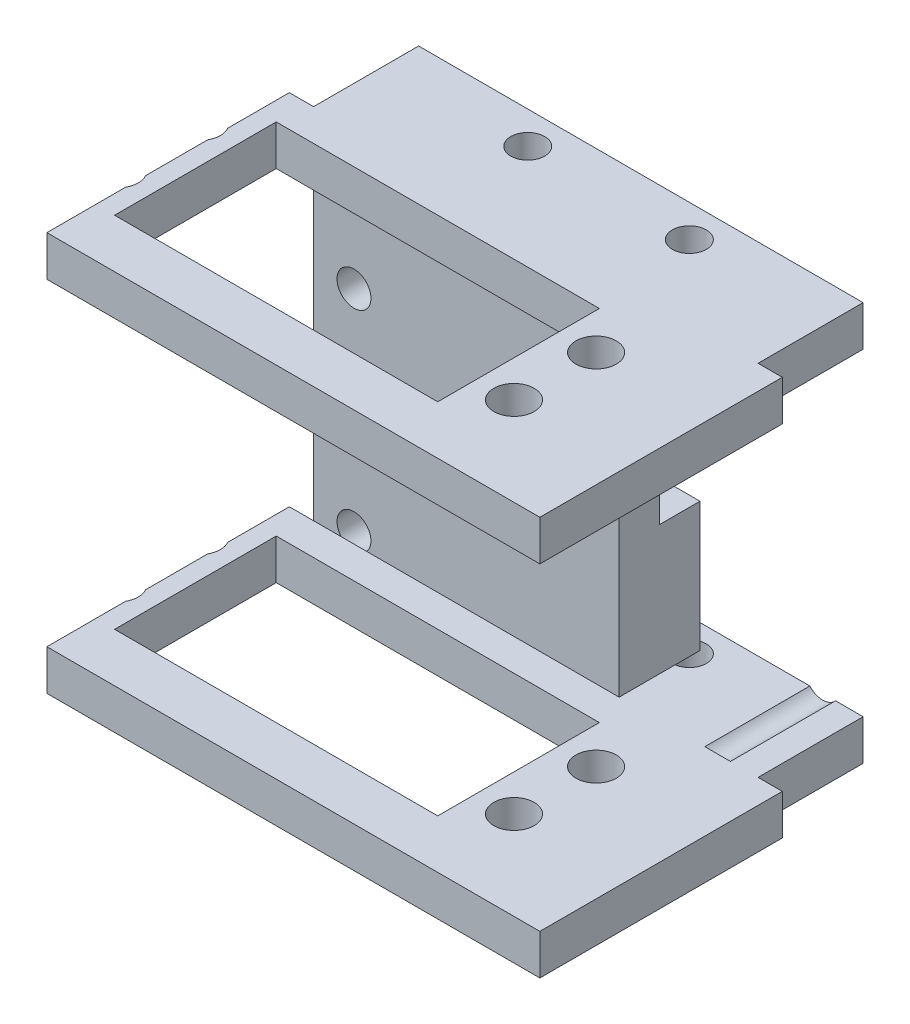
from build123d import *

# Parameters (mm, degrees)
BOSS_EXTRUDE1_DEPTH   = 5
BOSS_EXTRUDE1_2_DEPTH = 5
BOSS_EXTRUDE1_3_DEPTH = 5
BOSS_EXTRUDE1_4_DEPTH = 5
SKETCH2_W             = 37.8125
SKETCH2_H             = 39.375
BOSS_EXTRUDE2_DEPTH   = 5
SKETCH3_W             = 55
SKETCH3_H             = 13
SKETCH3_R             = 2.1
BOSS_EXTRUDE3_DEPTH   = 5
SKETCH4_W             = 61
SKETCH4_H             = 30
BOSS_EXTRUDE4_DEPTH   = 5
SKETCH5_R             = 2.5
SKETCH5_W             = 39.983210939
SKETCH5_H             = 20
CUT_EXTRUDE3_DEPTH    = 5
SKETCH7_R             = 2.1
CUT_EXTRUDE4_DEPTH    = 14


with BuildPart() as part:
    # Sketch1 → Boss-Extrude1 (new body)
    with BuildSketch(Plane.XY):
        with BuildLine():
            Line((16.390676557, 6.279692656), (19.828176557, 6.279692656))
            Line((19.828176557, 6.279692656), (19.828176557, 17.279692656))
            Line((19.828176557, 17.279692656), (13.640676557, 17.279692656))
            Line((13.640676557, 17.279692656), (13.640676557, 9.029692656))
            ThreePointArc((13.640676557, 9.029692656), (14.446132909, 7.085149007), (16.390676557, 6.279692656))
        make_face()
    extrude(amount=BOSS_EXTRUDE1_DEPTH)



with BuildPart() as body_2:
    # Sketch1 → Boss-Extrude1 2 (new body)
    with BuildSketch(Plane.XY):
        with BuildLine():
            Line((-17.984323443, 6.279692656), (-14.546823443, 6.279692656))
            ThreePointArc((-14.546823443, 6.279692656), (-12.602279794, 7.085149007), (-11.796823443, 9.029692656))
            Line((-11.796823443, 9.029692656), (-11.796823443, 17.279692656))
            Line((-11.796823443, 17.279692656), (-17.984323443, 17.279692656))
            Line((-17.984323443, 17.279692656), (-17.984323443, 6.279692656))
        make_face()
    extrude(amount=BOSS_EXTRUDE1_2_DEPTH)


with BuildPart() as body_3:
    # Sketch1 → Boss-Extrude1 3 (new body)
    with BuildSketch(Plane.XY):
        with BuildLine():
            Line((19.828176557, -6.095307344), (16.390676557, -6.095307344))
            ThreePointArc((16.390676557, -6.095307344), (14.446132909, -6.900763696), (13.640676557, -8.845307344))
            Line((13.640676557, -8.845307344), (13.640676557, -22.095307344))
            Line((13.640676557, -22.095307344), (19.828176557, -22.095307344))
            Line((19.828176557, -22.095307344), (19.828176557, -6.095307344))
        make_face()
    extrude(amount=BOSS_EXTRUDE1_3_DEPTH)


with BuildPart() as body_4:
    # Sketch1 → Boss-Extrude1 4 (new body)
    with BuildSketch(Plane.XY):
        with BuildLine():
            Line((-11.796823443, -17.095307344), (-11.796823443, -3.845307344))
            ThreePointArc((-11.796823443, -3.845307344), (-12.602279794, -1.900763696), (-14.546823443, -1.095307344))
            Line((-14.546823443, -1.095307344), (-17.984323443, -1.095307344))
            Line((-17.984323443, -1.095307344), (-17.984323443, -17.095307344))
            Line((-17.984323443, -17.095307344), (-11.796823443, -17.095307344))
        make_face()
    extrude(amount=BOSS_EXTRUDE1_4_DEPTH)


with BuildPart() as part_1:
    add(part.part)

    add(body_2.part)  # Boss-Extrude2 merges body 2

    add(body_3.part)  # Boss-Extrude2 merges body 3

    add(body_4.part)  # Boss-Extrude2 merges body 4
    # Sketch2 → Boss-Extrude2 (add)
    with BuildSketch(Plane.XY.offset(5)):
        with Locations((0.921926557, -2.407807344)):
            Rectangle(SKETCH2_W, SKETCH2_H)
    extrude(amount=BOSS_EXTRUDE2_DEPTH)

    # Sketch3 → Boss-Extrude3 (add)
    with BuildSketch(Plane(origin=(0, 17.279692656, 0), x_dir=(1, 0, 0), z_dir=(0, 1, 0))):
        with Locations((9.515676557, -3.5)):
            Rectangle(SKETCH3_W, SKETCH3_H)
        with Locations((-0.484323443, -1)):
            Circle(SKETCH3_R, mode=Mode.SUBTRACT)
        with Locations((19.515676557, -1)):
            Circle(SKETCH3_R, mode=Mode.SUBTRACT)
    boss_extrude3 = extrude(amount=BOSS_EXTRUDE3_DEPTH)

    # Mirror1: Boss-Extrude3 across plane
    add(boss_extrude3.mirror(Plane(origin=(0, -2.407807344, 0), x_dir=(0, 0, 1), z_dir=(0, -1, 0))))

    # Sketch4 → Boss-Extrude4 (add)
    with BuildSketch(Plane(origin=(0, 22.279692656, 0), x_dir=(1, 0, 0), z_dir=(0, 1, 0))):
        with Locations((9.515676557, -25)):
            Rectangle(SKETCH4_W, SKETCH4_H)
    boss_extrude4 = extrude(amount=-BOSS_EXTRUDE4_DEPTH)

    # Mirror2: Boss-Extrude4 across plane
    add(boss_extrude4.mirror(Plane(origin=(0, -2.407807344, 0), x_dir=(0, 0, 1), z_dir=(0, -1, 0))))

    # Sketch5 → Cut-Extrude3 (cut)
    with BuildSketch(Plane.XZ.offset(-17.279692656)):
        with Locations((-23.159015917, 29.025922811)):
            Circle(SKETCH5_R)
        with Locations((-23.159015917, 18.865922811)):
            Circle(SKETCH5_R)
        with Locations((25.840984083, 29.025922811)):
            Circle(SKETCH5_R)
        with Locations((25.840984083, 18.865922811)):
            Circle(SKETCH5_R)
        with Locations((1.332589552, 23.945922811)):
            Rectangle(SKETCH5_W, SKETCH5_H)
    cut_extrude3 = extrude(amount=-CUT_EXTRUDE3_DEPTH, mode=Mode.SUBTRACT)

    # Sketch7 → Cut-Extrude4 (cut, through all)
    with BuildSketch(Plane.XY.offset(10)):
        with Locations((32.015676557, -20.720307344)):
            Circle(SKETCH7_R)
        with Locations((-12.984323443, -20.720307344)):
            Circle(SKETCH7_R)
        with Locations((32.015676557, 5.279692656)):
            Circle(SKETCH7_R)
        with Locations((-12.984323443, 5.279692656)):
            Circle(SKETCH7_R)
    extrude(amount=-CUT_EXTRUDE4_DEPTH, mode=Mode.SUBTRACT)

    # Mirror3: Cut-Extrude3 across plane
    add(cut_extrude3.mirror(Plane(origin=(0, -2.407807344, 0), x_dir=(0, 0, 1), z_dir=(0, -1, 0))), mode=Mode.SUBTRACT)


solid = part_1.part
